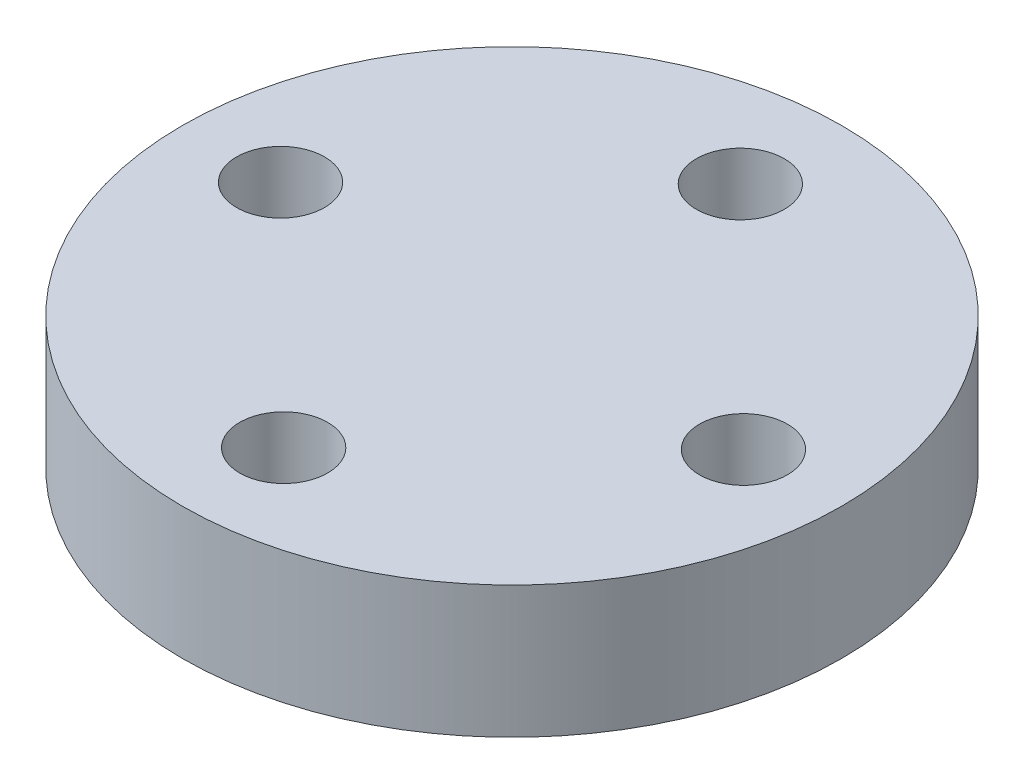
from build123d import *

# Parameters (mm, degrees)
SKETCH1_R           = 75
SKETCH1_R_2         = 10
BOSS_EXTRUDE1_DEPTH = 30
SKETCH2_R           = 20
BOSS_EXTRUDE2_DEPTH = 30
BOSS_EXTRUDE5_DEPTH = 60
CUT_EXTRUDE1_DEPTH  = 23


with BuildPart() as part:
    # Sketch1 → Boss-Extrude1 (new body)
    with BuildSketch(Plane(origin=(0, 0, 0), x_dir=(1, 0, 0), z_dir=(0, 1, 0))):
        Circle(SKETCH1_R)
        with Locations((0, -51.940298755)):
            Circle(SKETCH1_R_2, mode=Mode.SUBTRACT)
        with Locations((52.648575556, 0)):
            Circle(SKETCH1_R_2, mode=Mode.SUBTRACT)
        with Locations((-52.648575556, 0)):
            Circle(SKETCH1_R_2, mode=Mode.SUBTRACT)
        with Locations((0, 51.940298755)):
            Circle(SKETCH1_R_2, mode=Mode.SUBTRACT)
    extrude(amount=-BOSS_EXTRUDE1_DEPTH)

    # Sketch2 → Boss-Extrude2 (add)
    with BuildSketch(Plane.XZ.offset(30)):
        Circle(SKETCH2_R)
    extrude(amount=BOSS_EXTRUDE2_DEPTH)

    # Sketch3 → Boss-Extrude5 (add, through all)
    with BuildSketch(Plane.XZ.offset(60)):
        Polygon((2.130897014, 4.097878872), (-2.483418698, 3.894350383), (-4.614315712, -0.20352849), (-2.130897014, -4.097878872), (2.483418698, -3.894350383), (4.614315712, 0.20352849), align=None)
    extrude(amount=-BOSS_EXTRUDE5_DEPTH)

    # Sketch3_3 → Cut-Extrude1 (cut)
    with BuildSketch(Plane.XZ.offset(60)):
        Polygon((2.130897014, 4.097878872), (-2.483418698, 3.894350383), (-4.614315712, -0.20352849), (-2.130897014, -4.097878872), (2.483418698, -3.894350383), (4.614315712, 0.20352849), align=None)
    extrude(amount=-CUT_EXTRUDE1_DEPTH, mode=Mode.SUBTRACT)


solid = part.part
